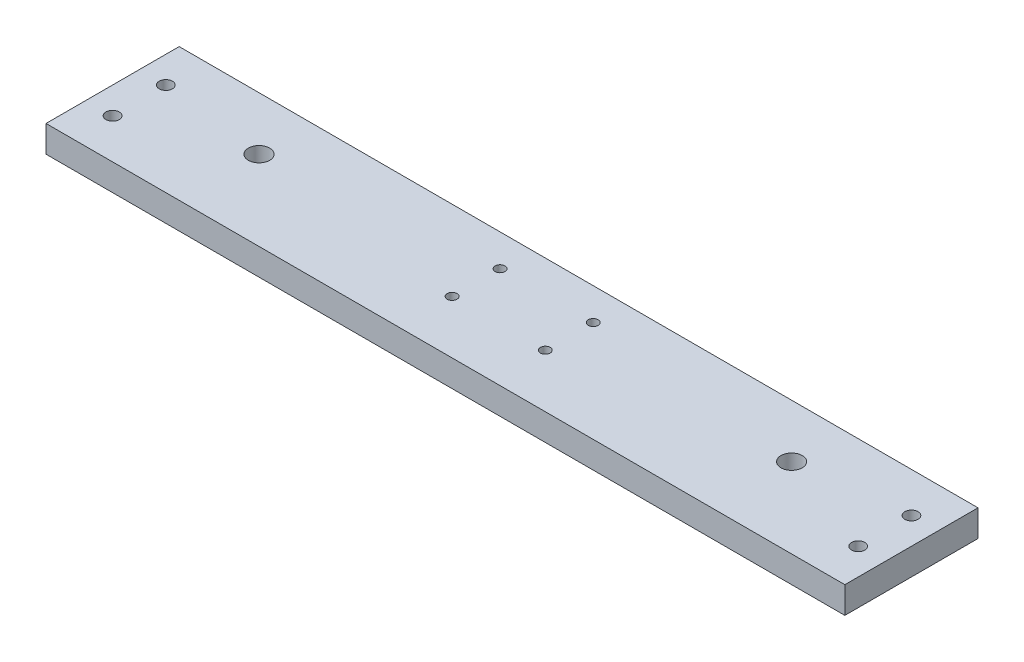
from build123d import *

# Parameters (mm, degrees)
SKETCH1_W           = 300
SKETCH1_H           = 50
SKETCH1_R           = 4
MAIN_DEPTH          = 10
SKETCH4_R           = 2.5
MOUNT_DEPTH         = 11
SKETCH3_R           = 1.85
BEARING_MOUNT_DEPTH = 11


with BuildPart() as part:
    # Sketch1 → main (new body)
    with BuildSketch(Plane(origin=(0, 0, 0), x_dir=(1, 0, 0), z_dir=(0, 1, 0))):
        with Locations((0, -5)):
            Rectangle(SKETCH1_W, SKETCH1_H)
        with Locations((-100, 0)):
            Circle(SKETCH1_R, mode=Mode.SUBTRACT)
        with Locations((100, 0)):
            Circle(SKETCH1_R, mode=Mode.SUBTRACT)
    extrude(amount=MAIN_DEPTH)

    # Sketch4 → mount (cut, through all)
    with BuildSketch(Plane(origin=(0, 10, 0), x_dir=(1, 0, 0), z_dir=(0, 1, 0))):
        with Locations((-140, 5)):
            Circle(SKETCH4_R)
        with Locations((-140, -15)):
            Circle(SKETCH4_R)
        with Locations((140, -15)):
            Circle(SKETCH4_R)
        with Locations((140, 5)):
            Circle(SKETCH4_R)
    extrude(amount=-MOUNT_DEPTH, mode=Mode.SUBTRACT)

    # Sketch3 → bearing_mount (cut, through all)
    with BuildSketch(Plane(origin=(0, 10, 0), x_dir=(1, 0, 0), z_dir=(0, 1, 0))):
        with Locations((-17.5, 8)):
            Circle(SKETCH3_R)
        with Locations((17.5, 8)):
            Circle(SKETCH3_R)
        with Locations((-17.5, -10)):
            Circle(SKETCH3_R)
        with Locations((17.5, -10)):
            Circle(SKETCH3_R)
    extrude(amount=-BEARING_MOUNT_DEPTH, mode=Mode.SUBTRACT)


solid = part.part
